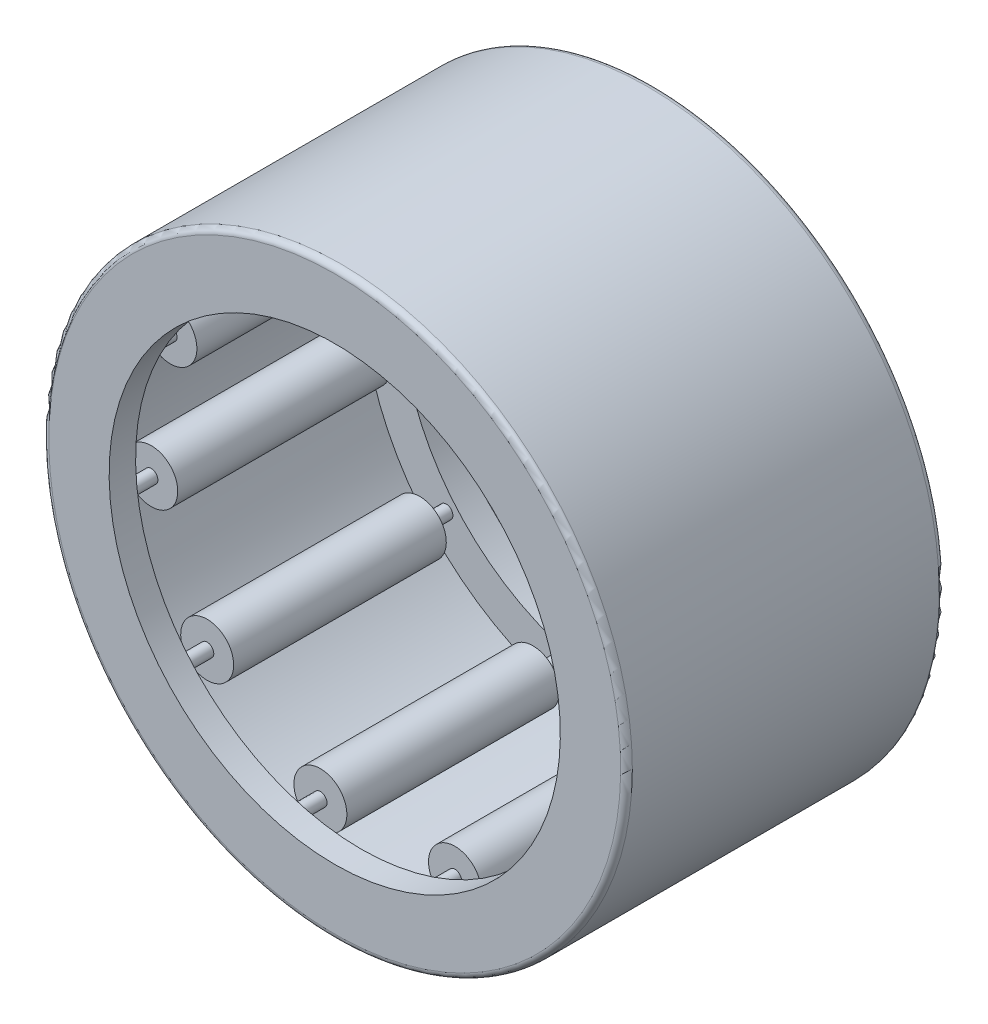
from build123d import *

# Parameters (mm, degrees)
SKETCH2_W         = 6.358466666
SKETCH2_H         = 0.593725
SKETCH3_W         = 7.941733334
SKETCH3_H         = 0.197908334
CIRPATTERN1_COUNT = 11
CIRPATTERN1_ANGLE = 327.272727273
FILLET1_R         = 0.174498


with BuildPart() as part:
    # Sketch1 → Revolve1 (revolve)
    with BuildSketch(Plane(origin=(0, 0, 0), x_dir=(0, 0, -1), z_dir=(1, 0, 0))):
        Polygon((-4.7625, 8.7249), (4.7625, 8.7249), (4.7625, 6.745816667), (3.970866667, 6.745816667), (3.970866667, 7.933266667), (-3.970866667, 7.933266667), (-3.970866667, 6.745816667), (-4.7625, 6.745816667), align=None)
    revolve(axis=Axis((0, 0, 4.7625), (0, 0, -1)))

    # Fillet1
    fillet1_edges = [part.edges().sort_by_distance(p)[0] for p in [
        (0, -8.7249, -4.7625),
        (0, -8.7249, 4.7625),
    ]]
    fillet(fillet1_edges, radius=FILLET1_R)


with BuildPart() as body_2:
    # Sketch2 → Revolve2 (revolve)
    with BuildSketch(Plane(origin=(0, 0, 0), x_dir=(0, 0, -1), z_dir=(1, 0, 0))):
        with Locations((0, 7.636404167)):
            Rectangle(SKETCH2_W, SKETCH2_H)
    revolve(axis=Axis((0, 7.141633333, 3.179233333), (0, 0, -1)))


with BuildPart() as body_3:
    # Sketch3 → Revolve3 (revolve)
    with BuildSketch(Plane(origin=(0, 0, 0), x_dir=(0, 0, -1), z_dir=(1, 0, 0))):
        with Locations((0, 7.2405875)):
            Rectangle(SKETCH3_W, SKETCH3_H)
    revolve(axis=Axis((0, 7.141633333, 3.970866667), (0, 0, -1)))


with BuildPart() as cirpattern1_1:
    # CirPattern1: pattern copy
    add(body_2.part.rotate(Axis((0, 0, -4.7625), (0, 0, 1)), 1 * CIRPATTERN1_ANGLE / (CIRPATTERN1_COUNT - 1)))


with BuildPart() as cirpattern1_2:
    # CirPattern1: pattern copy
    add(body_2.part.rotate(Axis((0, 0, -4.7625), (0, 0, 1)), 2 * CIRPATTERN1_ANGLE / (CIRPATTERN1_COUNT - 1)))


with BuildPart() as cirpattern1_3:
    # CirPattern1: pattern copy
    add(body_2.part.rotate(Axis((0, 0, -4.7625), (0, 0, 1)), 3 * CIRPATTERN1_ANGLE / (CIRPATTERN1_COUNT - 1)))


with BuildPart() as cirpattern1_4:
    # CirPattern1: pattern copy
    add(body_2.part.rotate(Axis((0, 0, -4.7625), (0, 0, 1)), 4 * CIRPATTERN1_ANGLE / (CIRPATTERN1_COUNT - 1)))


with BuildPart() as cirpattern1_5:
    # CirPattern1: pattern copy
    add(body_2.part.rotate(Axis((0, 0, -4.7625), (0, 0, 1)), 5 * CIRPATTERN1_ANGLE / (CIRPATTERN1_COUNT - 1)))


with BuildPart() as cirpattern1_6:
    # CirPattern1: pattern copy
    add(body_2.part.rotate(Axis((0, 0, -4.7625), (0, 0, 1)), 6 * CIRPATTERN1_ANGLE / (CIRPATTERN1_COUNT - 1)))


with BuildPart() as cirpattern1_7:
    # CirPattern1: pattern copy
    add(body_2.part.rotate(Axis((0, 0, -4.7625), (0, 0, 1)), 7 * CIRPATTERN1_ANGLE / (CIRPATTERN1_COUNT - 1)))


with BuildPart() as cirpattern1_8:
    # CirPattern1: pattern copy
    add(body_2.part.rotate(Axis((0, 0, -4.7625), (0, 0, 1)), 8 * CIRPATTERN1_ANGLE / (CIRPATTERN1_COUNT - 1)))


with BuildPart() as cirpattern1_9:
    # CirPattern1: pattern copy
    add(body_2.part.rotate(Axis((0, 0, -4.7625), (0, 0, 1)), 9 * CIRPATTERN1_ANGLE / (CIRPATTERN1_COUNT - 1)))


with BuildPart() as cirpattern1_10:
    # CirPattern1: pattern copy
    add(body_2.part.rotate(Axis((0, 0, -4.7625), (0, 0, 1)), 10 * CIRPATTERN1_ANGLE / (CIRPATTERN1_COUNT - 1)))


with BuildPart() as cirpattern1_11:
    # CirPattern1: pattern copy
    add(body_3.part.rotate(Axis((0, 0, -4.7625), (0, 0, 1)), 1 * CIRPATTERN1_ANGLE / (CIRPATTERN1_COUNT - 1)))


with BuildPart() as cirpattern1_12:
    # CirPattern1: pattern copy
    add(body_3.part.rotate(Axis((0, 0, -4.7625), (0, 0, 1)), 2 * CIRPATTERN1_ANGLE / (CIRPATTERN1_COUNT - 1)))


with BuildPart() as cirpattern1_13:
    # CirPattern1: pattern copy
    add(body_3.part.rotate(Axis((0, 0, -4.7625), (0, 0, 1)), 3 * CIRPATTERN1_ANGLE / (CIRPATTERN1_COUNT - 1)))


with BuildPart() as cirpattern1_14:
    # CirPattern1: pattern copy
    add(body_3.part.rotate(Axis((0, 0, -4.7625), (0, 0, 1)), 4 * CIRPATTERN1_ANGLE / (CIRPATTERN1_COUNT - 1)))


with BuildPart() as cirpattern1_15:
    # CirPattern1: pattern copy
    add(body_3.part.rotate(Axis((0, 0, -4.7625), (0, 0, 1)), 5 * CIRPATTERN1_ANGLE / (CIRPATTERN1_COUNT - 1)))


with BuildPart() as cirpattern1_16:
    # CirPattern1: pattern copy
    add(body_3.part.rotate(Axis((0, 0, -4.7625), (0, 0, 1)), 6 * CIRPATTERN1_ANGLE / (CIRPATTERN1_COUNT - 1)))


with BuildPart() as cirpattern1_17:
    # CirPattern1: pattern copy
    add(body_3.part.rotate(Axis((0, 0, -4.7625), (0, 0, 1)), 7 * CIRPATTERN1_ANGLE / (CIRPATTERN1_COUNT - 1)))


with BuildPart() as cirpattern1_18:
    # CirPattern1: pattern copy
    add(body_3.part.rotate(Axis((0, 0, -4.7625), (0, 0, 1)), 8 * CIRPATTERN1_ANGLE / (CIRPATTERN1_COUNT - 1)))


with BuildPart() as cirpattern1_19:
    # CirPattern1: pattern copy
    add(body_3.part.rotate(Axis((0, 0, -4.7625), (0, 0, 1)), 9 * CIRPATTERN1_ANGLE / (CIRPATTERN1_COUNT - 1)))


with BuildPart() as cirpattern1_20:
    # CirPattern1: pattern copy
    add(body_3.part.rotate(Axis((0, 0, -4.7625), (0, 0, 1)), 10 * CIRPATTERN1_ANGLE / (CIRPATTERN1_COUNT - 1)))


solid = Compound([part.part, body_2.part, body_3.part, cirpattern1_1.part, cirpattern1_2.part, cirpattern1_3.part, cirpattern1_4.part, cirpattern1_5.part, cirpattern1_6.part, cirpattern1_7.part, cirpattern1_8.part, cirpattern1_9.part, cirpattern1_10.part, cirpattern1_11.part, cirpattern1_12.part, cirpattern1_13.part, cirpattern1_14.part, cirpattern1_15.part, cirpattern1_16.part, cirpattern1_17.part, cirpattern1_18.part, cirpattern1_19.part, cirpattern1_20.part])
